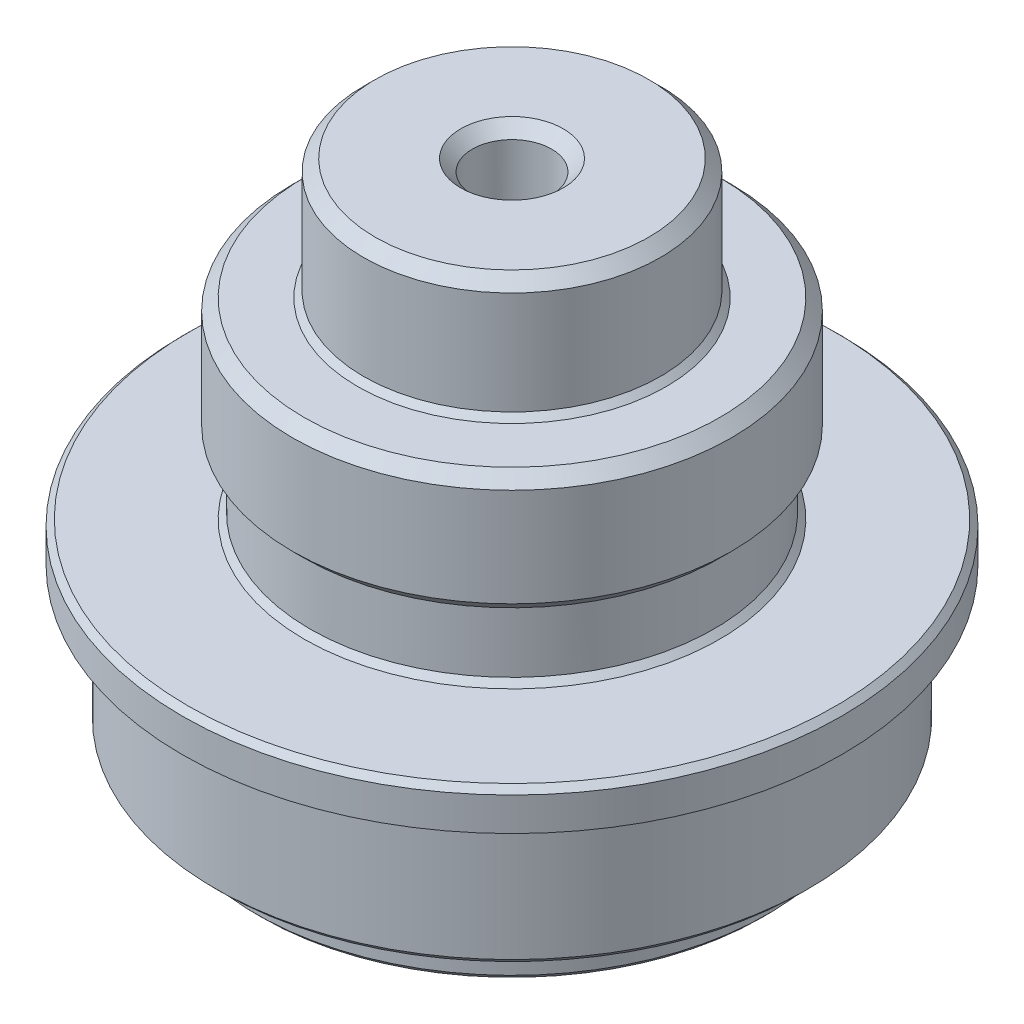
from build123d import *

# Parameters (mm, degrees)
CHAMFER2_SIZE = 1
CHAMFER3_SIZE = 1
CHAMFER4_SIZE = 0.5


with BuildPart() as part:
    # Sketch1 → Revolve1 (revolve)
    with BuildSketch(Plane.XY):
        Polygon((0, 28), (0, 26.629648104), (14.528640902, 26.629648104), (14.528640902, 0), (21.838640902, 0), (21.838640902, 3.65), (25.35, 3.65), (25.35, 15.45), (28.147407407, 15.45), (28.147407407, 18.8), (17.25, 18.8), (17.25, 24.8), (18.75, 24.8), (18.75, 35.2), (12.68, 35.2), (12.68, 45.5), (3.38, 45.5), (3.38, 28), align=None)
    revolve(axis=Axis((0, 0, 0), (0, 1, 0)))

    # Chamfer2
    chamfer2_edges = [part.edges().sort_by_distance(p)[0] for p in [
        (-3.38, 45.5, 0),
        (-18.75, 35.2, 0),
        (-18.75, 24.8, 0),
    ]]
    chamfer(chamfer2_edges, length=CHAMFER2_SIZE)

    # Chamfer3
    chamfer3_edges = [part.edges().sort_by_distance(p)[0] for p in [
        (-12.68, 45.5, 0),
    ]]
    chamfer(chamfer3_edges, length=CHAMFER3_SIZE)

    # Chamfer4
    chamfer4_edges = [part.edges().sort_by_distance(p)[0] for p in [
        (-12.68, 35.2, 0),
        (-17.25, 18.8, 0),
        (-28.147407407, 18.8, 0),
        (-25.35, 3.65, 0),
        (-21.838640902, 0, 0),
        (-14.528640902, 0, 0),
    ]]
    chamfer(chamfer4_edges, length=CHAMFER4_SIZE)


solid = part.part
